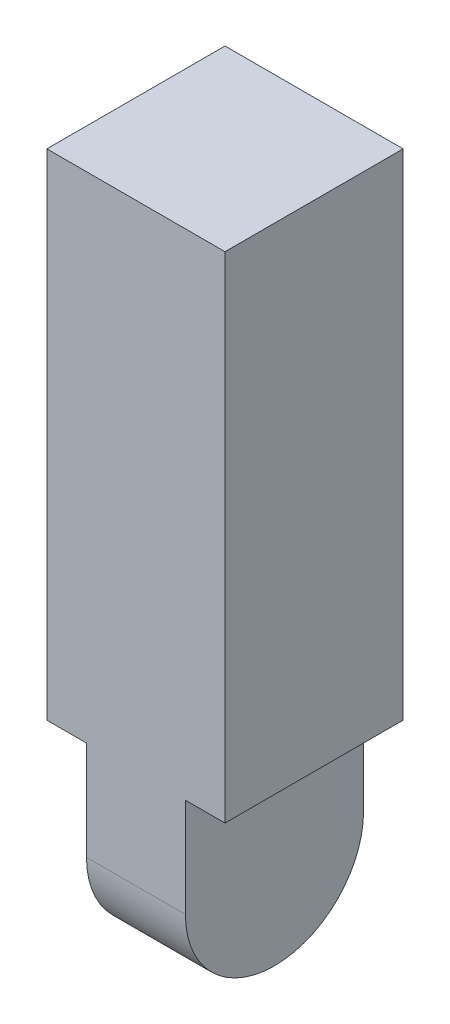
from build123d import *

# Parameters (mm, degrees)
SKETCH_1_W      = 18
SKETCH_1_H      = 18
EXTRUDE_1_DEPTH = 50
EXTRUDE_2_DEPTH = 5


with BuildPart() as part:
    # 草图1 → 凸台-拉伸1 (new body)
    with BuildSketch(Plane(origin=(0, 0, 0), x_dir=(1, 0, 0), z_dir=(0, 1, 0))):
        Rectangle(SKETCH_1_W, SKETCH_1_H)
    extrude(amount=EXTRUDE_1_DEPTH)

    # 草图2 → 凸台-拉伸2 (add, symmetric)
    with BuildSketch(Plane(origin=(0, 0, 0), x_dir=(0, 0, -1), z_dir=(1, 0, 0))):
        with BuildLine():
            Line((-9, -10), (-9, 1.037830192))
            Line((-9, 1.037830192), (9, 1.037830192))
            Line((9, 1.037830192), (9, -10))
            ThreePointArc((9, -10), (0, -19), (-9, -10))
        make_face()
    extrude(amount=EXTRUDE_2_DEPTH, both=True)


solid = part.part
